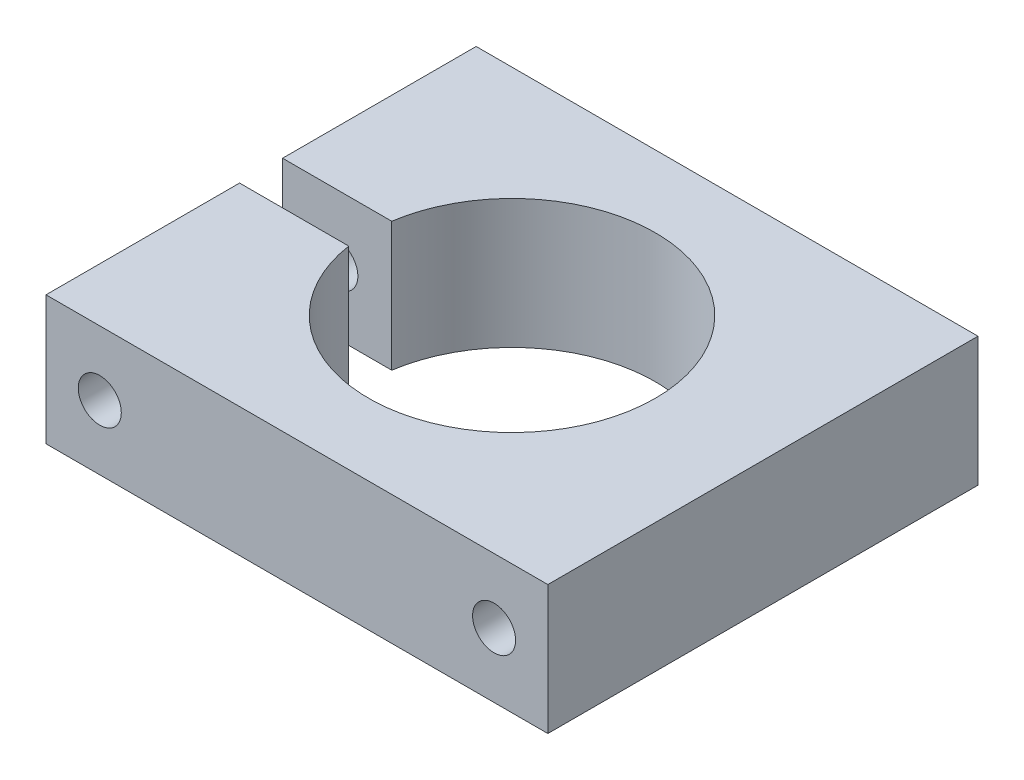
from build123d import *

# Parameters (mm, degrees)
BOSS_EXTRUDE1_DEPTH = 18
SKETCH2_R           = 3
CUT_EXTRUDE1_DEPTH  = 61


with BuildPart() as part:
    # Sketch1 → Boss-Extrude1 (new body)
    with BuildSketch(Plane(origin=(0, 0, 0), x_dir=(1, 0, 0), z_dir=(0, 1, 0))):
        with BuildLine():
            Line((-35, 30), (35, 30))
            Line((35, 30), (35, -30))
            Line((35, -30), (-35, -30))
            Line((-35, -30), (-35, -3))
            Line((-35, -3), (-19.773719933, -3))
            ThreePointArc((-19.773719933, -3), (20, 0), (-19.773719933, 3))
            Line((-19.773719933, 3), (-35, 3))
            Line((-35, 3), (-35, 30))
        make_face()
    extrude(amount=BOSS_EXTRUDE1_DEPTH)

    # Sketch2 → Cut-Extrude1 (cut, through all)
    with BuildSketch(Plane.XY.offset(30)):
        with Locations((27.5, 9)):
            Circle(SKETCH2_R)
        with Locations((-27.5, 9)):
            Circle(SKETCH2_R)
    extrude(amount=-CUT_EXTRUDE1_DEPTH, mode=Mode.SUBTRACT)


solid = part.part
